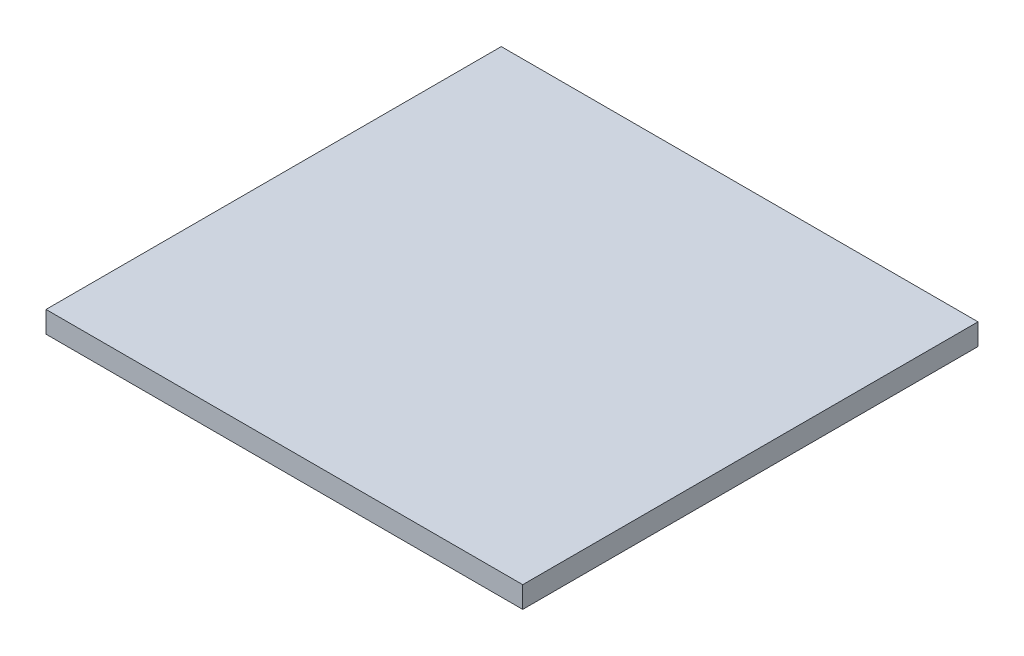
from build123d import *

# Parameters (mm, degrees)
SKETCH_1_W      = 200
SKETCH_1_H      = 191
EXTRUDE_1_DEPTH = 9


with BuildPart() as part:
    # 草图1 → 凸台-拉伸1 (new body)
    with BuildSketch(Plane(origin=(0, 0, 0), x_dir=(1, 0, 0), z_dir=(0, 1, 0))):
        Rectangle(SKETCH_1_W, SKETCH_1_H)
    extrude(amount=EXTRUDE_1_DEPTH)


solid = part.part
